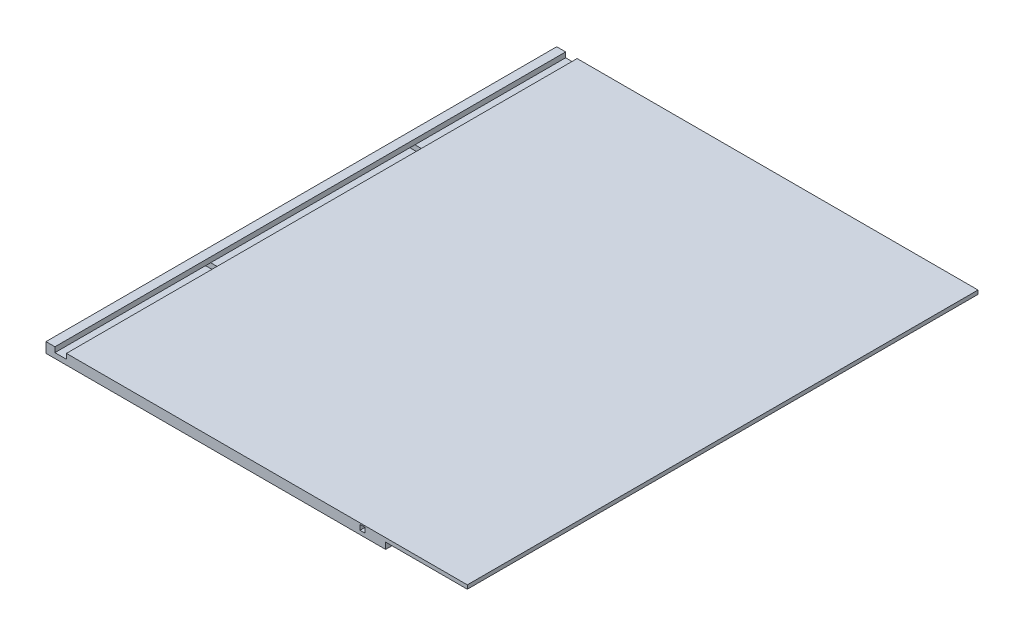
from build123d import *

# Parameters (mm, degrees)
SKETCH1_W           = 2095.5
SKETCH1_H           = 2540
BOSS_EXTRUDE1_DEPTH = 50.8
SKETCH2_W           = 57.15
SKETCH2_H           = 25.4
SKETCH2_W_2         = 406.4
SKETCH2_H_2         = 31.75
SKETCH2_W_3         = 25.4
CUT_EXTRUDE1_DEPTH  = 2540
SKETCH3_W           = 25.4
SKETCH3_H           = 25.4
CUT_EXTRUDE2_DEPTH  = 2095.5


with BuildPart() as part:
    # Sketch1 → Boss-Extrude1 (new body)
    with BuildSketch(Plane(origin=(0, 0, 0), x_dir=(1, 0, 0), z_dir=(0, 1, 0))):
        Rectangle(SKETCH1_W, SKETCH1_H)
    extrude(amount=BOSS_EXTRUDE1_DEPTH)

    # Sketch2 → Cut-Extrude1 (cut)
    with BuildSketch(Plane.XY.offset(1270)):
        with Locations((-974.725, 38.1)):
            Rectangle(SKETCH2_W, SKETCH2_H)
        with Locations((844.55, 15.875)):
            Rectangle(SKETCH2_W_2, SKETCH2_H_2)
        with Locations((527.05, 31.75)):
            Rectangle(SKETCH2_W_3, SKETCH2_H)
    extrude(amount=-CUT_EXTRUDE1_DEPTH, mode=Mode.SUBTRACT)

    # Sketch3 → Cut-Extrude2 (cut)
    with BuildSketch(Plane.ZY.offset(1047.75)):
        with Locations((-508, 12.7)):
            Rectangle(SKETCH3_W, SKETCH3_H)
        with Locations((508, 12.7)):
            Rectangle(SKETCH3_W, SKETCH3_H)
    extrude(amount=-CUT_EXTRUDE2_DEPTH, mode=Mode.SUBTRACT)


solid = part.part
